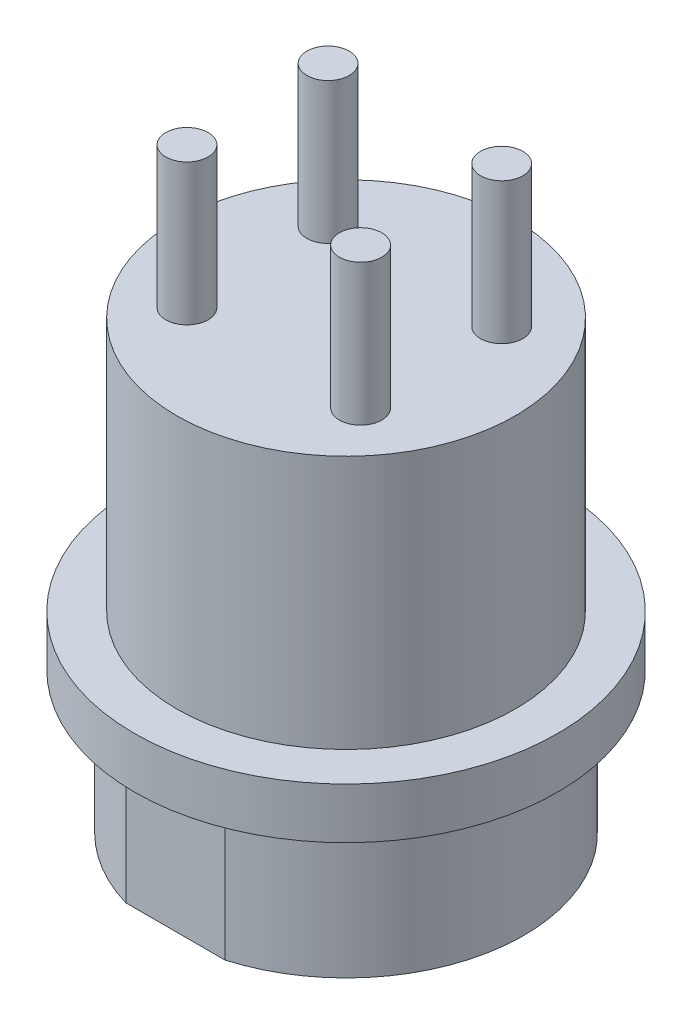
from build123d import *

# Parameters (mm, degrees)
SKETCH1_R           = 6.3
BOSS_EXTRUDE1_DEPTH = 5
SKETCH2_R           = 7.5
BOSS_EXTRUDE2_DEPTH = 1.8
SKETCH3_R           = 6
BOSS_EXTRUDE3_DEPTH = 9
SKETCH4_R           = 4.5
CUT_EXTRUDE1_DEPTH  = 10
BOSS_EXTRUDE4_DEPTH = 10
SKETCH6_R           = 0.5
BOSS_EXTRUDE5_DEPTH = 8
FILLET1_R           = 0.2
SKETCH7_R           = 0.75
BOSS_EXTRUDE6_DEPTH = 5
SKETCH8_W           = 10
SKETCH8_H           = 0.5
SKETCH8_H_2         = 1.079785018
CUT_EXTRUDE2_DEPTH  = 5


with BuildPart() as part:
    # Sketch1 → Boss-Extrude1 (new body)
    with BuildSketch(Plane(origin=(0, 0, 0), x_dir=(1, 0, 0), z_dir=(0, 1, 0))):
        Circle(SKETCH1_R)
    extrude(amount=BOSS_EXTRUDE1_DEPTH)

    # Sketch2 → Boss-Extrude2 (add)
    with BuildSketch(Plane(origin=(0, 5, 0), x_dir=(1, 0, 0), z_dir=(0, 1, 0))):
        Circle(SKETCH2_R)
    extrude(amount=BOSS_EXTRUDE2_DEPTH)

    # Sketch3 → Boss-Extrude3 (add)
    with BuildSketch(Plane(origin=(0, 6.8, 0), x_dir=(1, 0, 0), z_dir=(0, 1, 0))):
        Circle(SKETCH3_R)
    extrude(amount=BOSS_EXTRUDE3_DEPTH)

    # Sketch4 → Cut-Extrude1 (cut)
    with BuildSketch(Plane.XZ):
        Circle(SKETCH4_R)
    extrude(amount=-CUT_EXTRUDE1_DEPTH, mode=Mode.SUBTRACT)

    # Sketch5 → Boss-Extrude4 (add)
    with BuildSketch(Plane.XZ.offset(-10)):
        with BuildLine():
            Line((-0.5, 4.5), (0.5, 4.5))
            ThreePointArc((0.5, 4.5), (0, 4), (-0.5, 4.5))
        make_face()
    extrude(amount=BOSS_EXTRUDE4_DEPTH)

    # Sketch6 → Boss-Extrude5 (add)
    with BuildSketch(Plane.XZ.offset(-10)):
        with Locations((-2, 2)):
            Circle(SKETCH6_R)
        with Locations((2, 2)):
            Circle(SKETCH6_R)
        with Locations((2, -2)):
            Circle(SKETCH6_R)
        with Locations((-2, -2)):
            Circle(SKETCH6_R)
    extrude(amount=BOSS_EXTRUDE5_DEPTH)

    # Fillet1
    fillet1_edges = [part.edges().sort_by_distance(p)[0] for p in [
        (-2.5, 2, 2),
        (1.5, 2, 2),
        (1.5, 2, -2),
        (-2.5, 2, -2),
    ]]
    fillet(fillet1_edges, radius=FILLET1_R)

    # Sketch7 → Boss-Extrude6 (add)
    with BuildSketch(Plane(origin=(0, 15.8, 0), x_dir=(1, 0, 0), z_dir=(0, 1, 0))):
        with Locations((-3.138015201, 2.5)):
            Circle(SKETCH7_R)
        with Locations((-3.138015201, -2.5)):
            Circle(SKETCH7_R)
        with Locations((3.015436482, -2.5)):
            Circle(SKETCH7_R)
        with Locations((3.015436482, 2.5)):
            Circle(SKETCH7_R)
    extrude(amount=BOSS_EXTRUDE6_DEPTH)

    # Sketch8 → Cut-Extrude2 (cut)
    with BuildSketch(Plane.XZ):
        with Locations((0, 6.3)):
            Rectangle(SKETCH8_W, SKETCH8_H)
        with Locations((0, -6.3)):
            Rectangle(SKETCH8_W, SKETCH8_H_2)
    extrude(amount=-CUT_EXTRUDE2_DEPTH, mode=Mode.SUBTRACT)


solid = part.part
